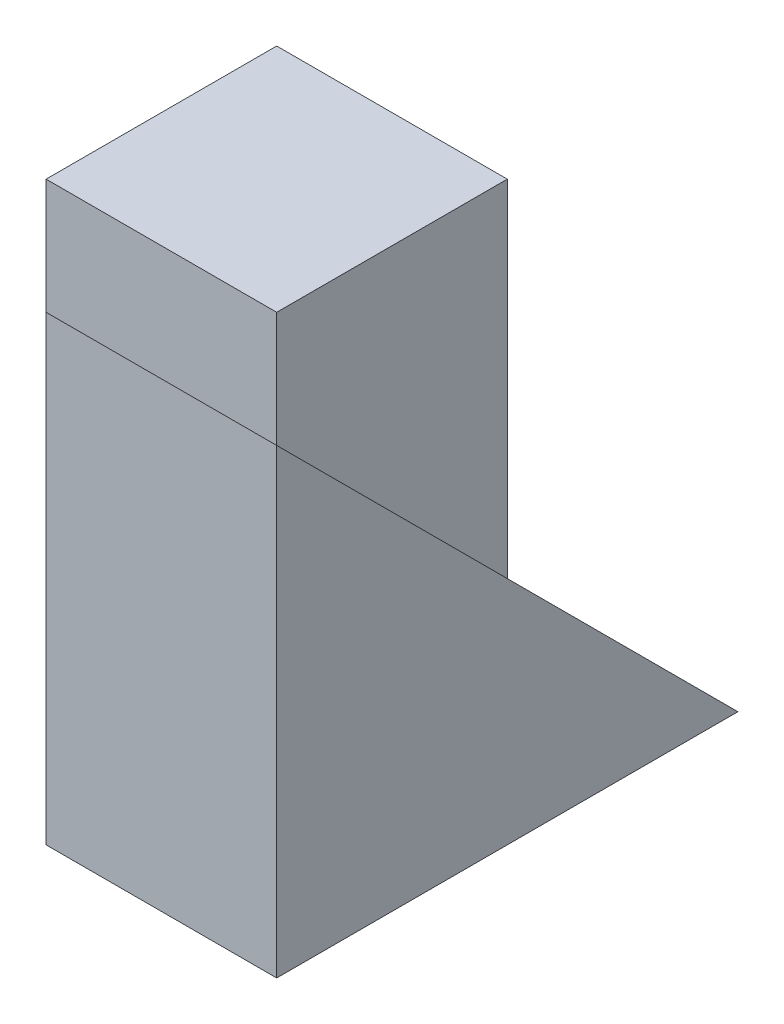
from build123d import *

# Parameters (mm, degrees)
SKETCH1_W           = 4
SKETCH1_H           = 4
BOSS_EXTRUDE1_DEPTH = 2
SKETCH2_W           = 2
SKETCH2_H           = 3
BOSS_EXTRUDE2_DEPTH = 2
CUT_EXTRUDE2_DEPTH  = 2


with BuildPart() as part:
    # Sketch1 → Boss-Extrude1 (new body)
    with BuildSketch(Plane(origin=(0, 0, 0), x_dir=(0, 0, -1), z_dir=(1, 0, 0))):
        with Locations((2, 2)):
            Rectangle(SKETCH1_W, SKETCH1_H)
    extrude(amount=BOSS_EXTRUDE1_DEPTH)

    # Sketch2 → Boss-Extrude2 (add)
    with BuildSketch(Plane.ZY):
        with Locations((-3, 1.5)):
            Rectangle(SKETCH2_W, SKETCH2_H)
    extrude(amount=BOSS_EXTRUDE2_DEPTH)

    # Sketch3 → Cut-Extrude2 (cut)
    with BuildSketch(Plane(origin=(2, 0, 0), x_dir=(0, 0, -1), z_dir=(1, 0, 0))):
        Polygon((0, 4), (4, 0), (4, 4), align=None)
    extrude(amount=-CUT_EXTRUDE2_DEPTH, mode=Mode.SUBTRACT)


solid = part.part
